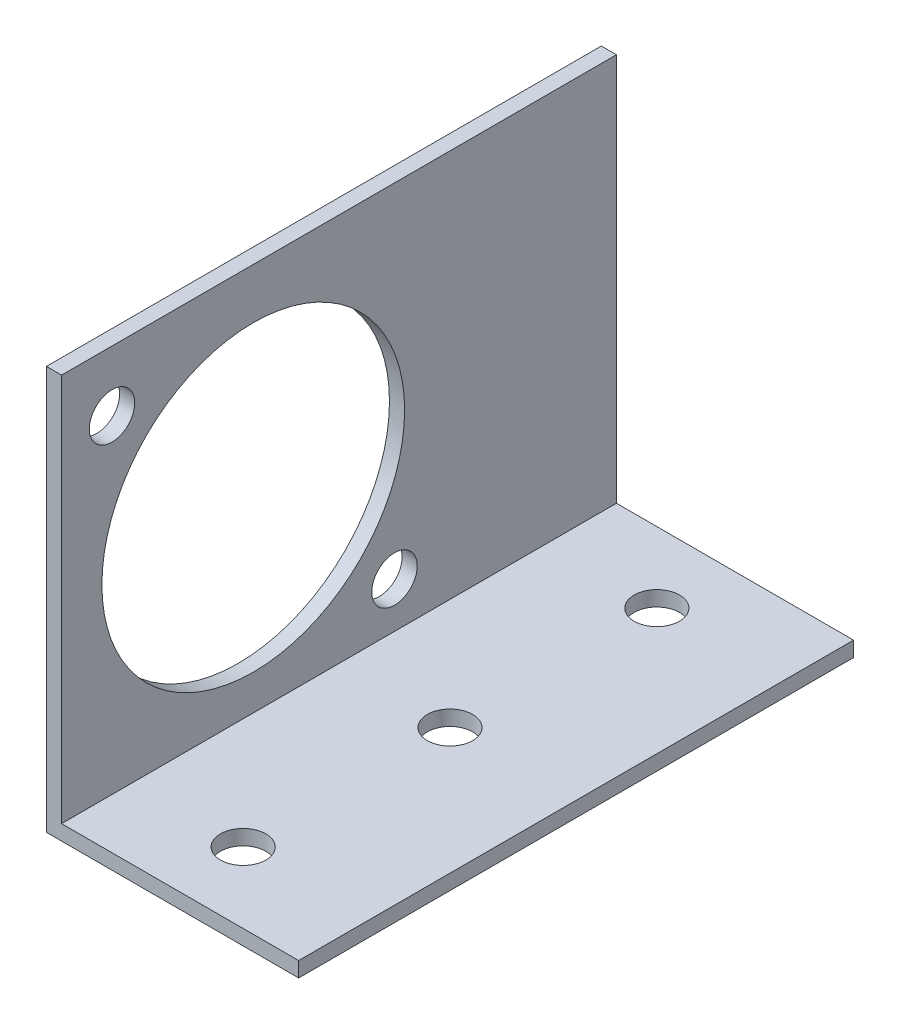
from build123d import *

# Parameters (mm, degrees)
EXTRU_MINCE1_DEPTH    = 55
D_GAGEMENT_M41_D      = 4.5
D_GAGEMENT_M42_D      = 4.5
D_GAGEMENT_M271_D     = 30
D_GAGEMENT_M271_DEPTH = 1.5
D_GAGEMENT_M271_TIP   = 9.012909285


with BuildPart() as part:
    # Esquisse1 → Extru.-Mince1 (new body)
    with BuildSketch(Plane.XY):
        Polygon((0, 40), (0, 0), (25, 0), (25, 1.5), (1.5, 1.5), (1.5, 40), align=None)
    extrude(amount=-EXTRU_MINCE1_DEPTH)

    # Dégagement M41 (through all)
    with Locations(Plane(origin=(0, 1.5, 0), x_dir=(-1, 0, 0), z_dir=(0, 1, 0))):
        with Locations((-12.5, -7), (-12.5, -27.5), (-12.5, -48)):
            Hole(D_GAGEMENT_M41_D / 2)

    # Dégagement M42 (through all)
    with Locations(Plane(origin=(1.5, 0, 0), x_dir=(0, 0, -1), z_dir=(1, 0, 0))):
        with Locations((5, 34), (33, 6)):
            Hole(D_GAGEMENT_M42_D / 2)

    # Dégagement M271
    with Locations(Plane(origin=(1.5, 0, 0), x_dir=(0, 0, -1), z_dir=(1, 0, 0))):
        with Locations((19, 20)):
            Hole(D_GAGEMENT_M271_D / 2, depth=D_GAGEMENT_M271_DEPTH)
            with Locations((0, 0, -(D_GAGEMENT_M271_DEPTH + D_GAGEMENT_M271_TIP / 2))):  # 118° drill point
                Cone(0, D_GAGEMENT_M271_D / 2, D_GAGEMENT_M271_TIP, mode=Mode.SUBTRACT)


solid = part.part
